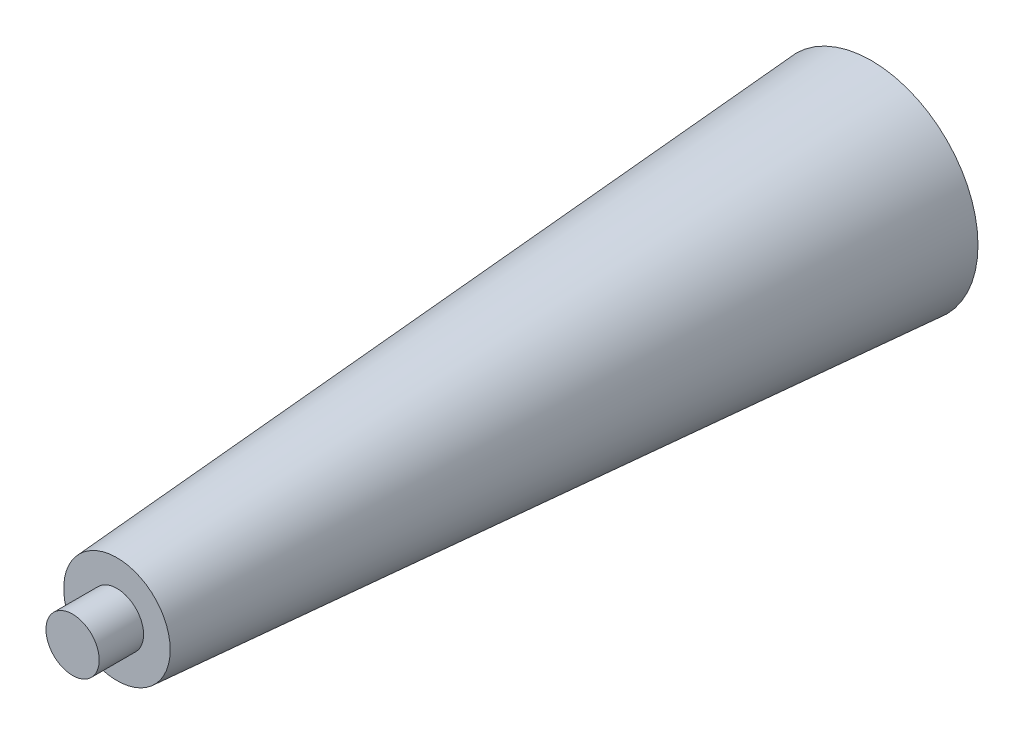
from build123d import *

# Parameters (mm, degrees)
IZIM3_R                     = 3
Y_KSEKLIK_EKSTR_ZYON1_DEPTH = 5


with BuildPart() as part:
    # Çizim2 → Döndür1 (revolve)
    with BuildSketch(Plane(origin=(0, 0, 0), x_dir=(1, 0, 0), z_dir=(0, 1, 0))):
        Polygon((0, 0), (12, 0), (6, -85), (0, -85), align=None)
    revolve(axis=Axis((0, 0, 89.25), (0, 0, -1)))

    # Çizim3 → Yükseklik-Ekstrüzyon1 (add)
    with BuildSketch(Plane.XY.offset(85)):
        Circle(IZIM3_R)
    extrude(amount=Y_KSEKLIK_EKSTR_ZYON1_DEPTH)


solid = part.part
